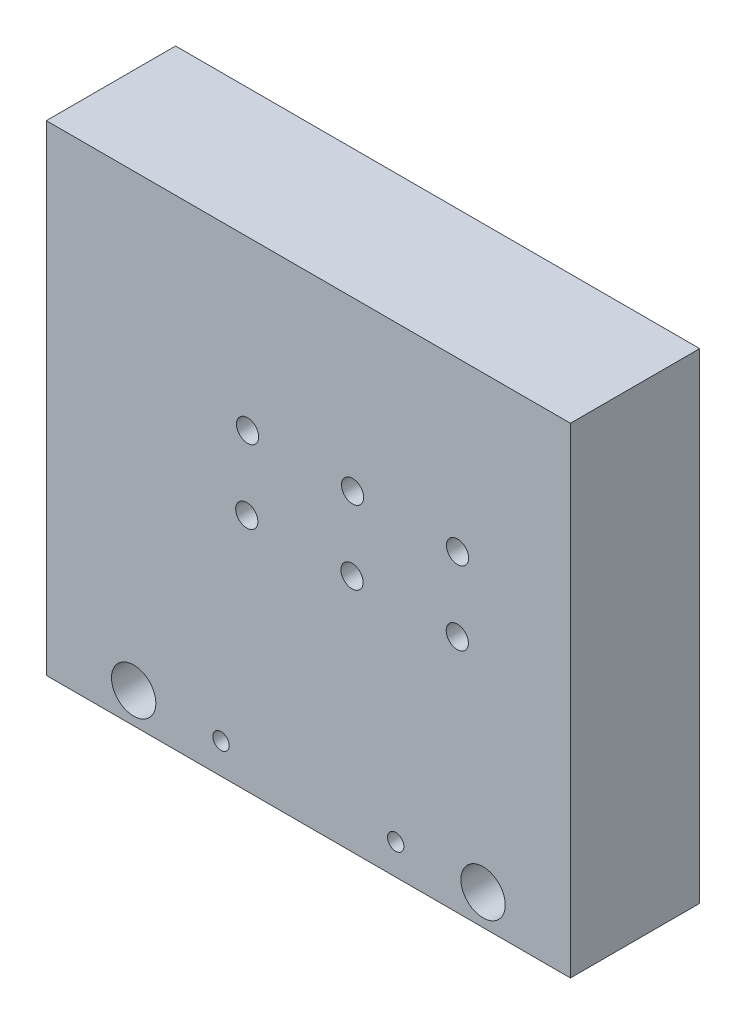
from build123d import *

# Parameters (mm, degrees)
SKETCH1_W           = 300
SKETCH1_H           = 275
SKETCH1_R           = 12.7
SKETCH1_R_2         = 4.675
SKETCH1_R_3         = 3
BOSS_EXTRUDE1_DEPTH = 74
SKETCH2_R           = 6.35
CUT_EXTRUDE1_DEPTH  = 45


with BuildPart() as part:
    # Sketch1 → Boss-Extrude1 (new body)
    with BuildSketch(Plane.XY):
        with Locations((150, 137.5)):
            Rectangle(SKETCH1_W, SKETCH1_H)
        with Locations((250, 17.5)):
            Circle(SKETCH1_R, mode=Mode.SUBTRACT)
        with Locations((200, 17.5)):
            Circle(SKETCH1_R_2, mode=Mode.SUBTRACT)
        with Locations((100, 17.5)):
            Circle(SKETCH1_R_2, mode=Mode.SUBTRACT)
        with Locations((50, 17.5)):
            Circle(SKETCH1_R, mode=Mode.SUBTRACT)
        with Locations((235.25, 136.75)):
            Circle(SKETCH1_R_3, mode=Mode.SUBTRACT)
        with Locations((114.75, 136.75)):
            Circle(SKETCH1_R_3, mode=Mode.SUBTRACT)
        with Locations((175, 136.75)):
            Circle(SKETCH1_R_3, mode=Mode.SUBTRACT)
        with Locations((115.210881667, 178.997486175)):
            Circle(SKETCH1_R_3, mode=Mode.SUBTRACT)
        with Locations((175.307264601, 178.998882689)):
            Circle(SKETCH1_R_3, mode=Mode.SUBTRACT)
        with Locations((235.403635348, 178.999720664)):
            Circle(SKETCH1_R_3, mode=Mode.SUBTRACT)
    extrude(amount=BOSS_EXTRUDE1_DEPTH)

    # Sketch2 → Cut-Extrude1 (cut)
    with BuildSketch(Plane(origin=(0, 0, 74), x_dir=(-1, 0, 0), z_dir=(0, 0, -1))):
        with Locations((-175, 136.75)):
            Circle(SKETCH2_R)
        with Locations((-235.25, 136.75)):
            Circle(SKETCH2_R)
        with Locations((-235.403635348, 178.999720664)):
            Circle(SKETCH2_R)
        with Locations((-175.307264601, 178.998882689)):
            Circle(SKETCH2_R)
        with Locations((-115.210881667, 178.997486175)):
            Circle(SKETCH2_R)
        with Locations((-114.75, 136.75)):
            Circle(SKETCH2_R)
    extrude(amount=CUT_EXTRUDE1_DEPTH, mode=Mode.SUBTRACT)


solid = part.part
